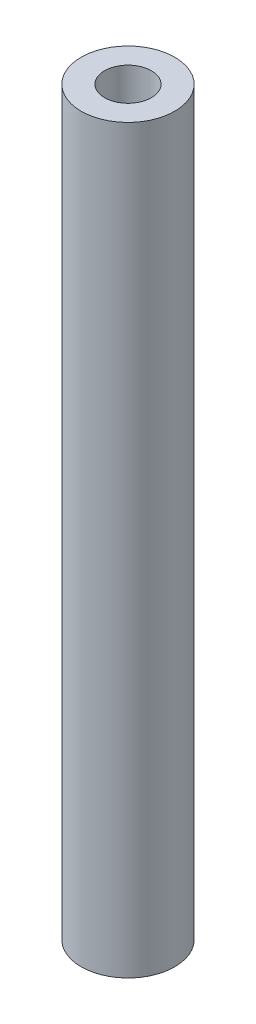
from build123d import *

# Parameters (mm, degrees)
SKETCH1_R           = 6
SKETCH1_R_2         = 3
BOSS_EXTRUDE1_DEPTH = 95


with BuildPart() as part:
    # Sketch1 → Boss-Extrude1 (new body)
    with BuildSketch(Plane(origin=(0, 0, 0), x_dir=(1, 0, 0), z_dir=(0, 1, 0))):
        Circle(SKETCH1_R)
        Circle(SKETCH1_R_2, mode=Mode.SUBTRACT)
    extrude(amount=BOSS_EXTRUDE1_DEPTH)


solid = part.part
